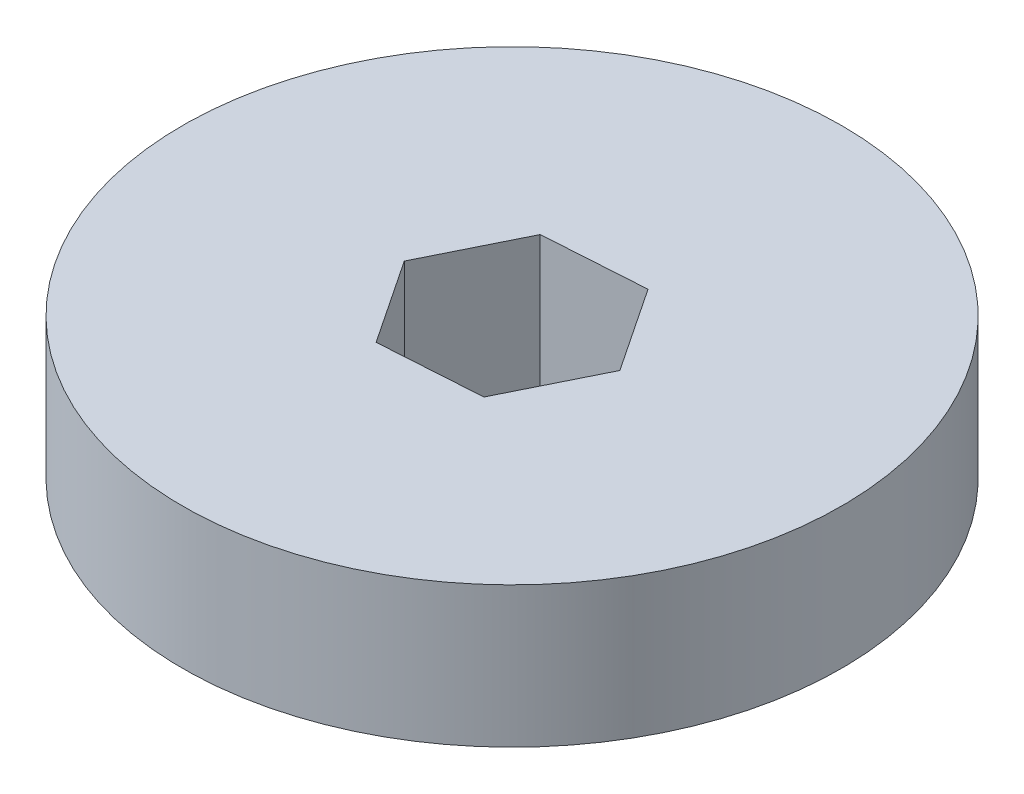
from build123d import *

# Parameters (mm, degrees)
SKETCH1_R           = 30.1625
BOSS_EXTRUDE1_DEPTH = 10.16
CUT_EXTRUDE1_DEPTH  = 11.16
SKETCH3_R           = 30.1625
SKETCH3_R_2         = 23.8125
CUT_EXTRUDE2_DEPTH  = 11.16


with BuildPart() as part:
    # Sketch1 → Boss-Extrude1 (new body)
    with BuildSketch(Plane(origin=(0, 0, 0), x_dir=(1, 0, 0), z_dir=(0, 1, 0))):
        Circle(SKETCH1_R)
    extrude(amount=BOSS_EXTRUDE1_DEPTH)

    # Sketch2 → Cut-Extrude1 (cut, through all)
    with BuildSketch(Plane(origin=(0, 10.16, 0), x_dir=(1, 0, 0), z_dir=(0, 1, 0))):
        Polygon((4.067255107, -6.10088266), (7.317146922, 0.471904916), (3.249891816, 6.572787576), (-4.067255107, 6.10088266), (-7.317146922, -0.471904916), (-3.249891816, -6.572787576), align=None)
    extrude(amount=-CUT_EXTRUDE1_DEPTH, mode=Mode.SUBTRACT)

    # Sketch3 → Cut-Extrude2 (cut, through all)
    with BuildSketch(Plane(origin=(0, 0, 0), x_dir=(-1, 0, 0), z_dir=(0, -1, 0))):
        Circle(SKETCH3_R)
        Circle(SKETCH3_R_2, mode=Mode.SUBTRACT)
    extrude(amount=-CUT_EXTRUDE2_DEPTH, mode=Mode.SUBTRACT)


solid = part.part
